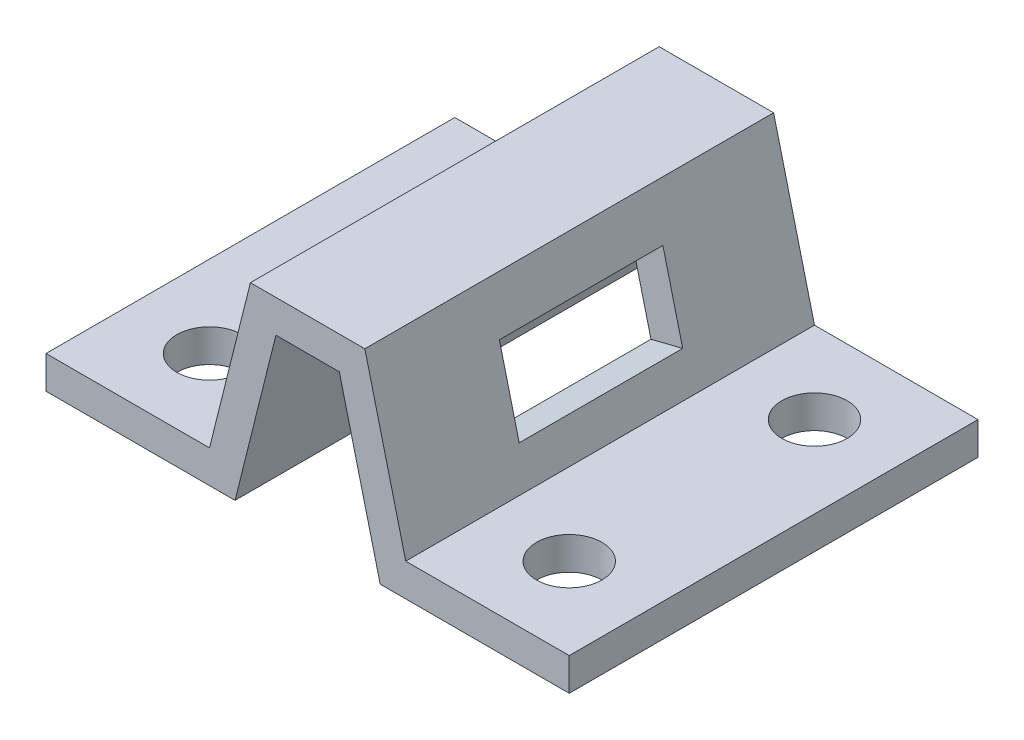
from build123d import *

# Parameters (mm, degrees)
BOSS_EXTRUDE1_DEPTH = 62.5
SKETCH3_R           = 10
CUT_EXTRUDE1_DEPTH  = 125
SKETCH4_W           = 50
SKETCH4_H           = 25
CUT_EXTRUDE2_DEPTH  = 10
SKETCH5_W           = 50
SKETCH5_H           = 25
CUT_EXTRUDE3_DEPTH  = 10


with BuildPart() as part:
    # Sketch2 → Boss-Extrude1 (new body, symmetric)
    with BuildSketch(Plane.XY):
        Polygon((-17.5, 60), (17.5, 60), (30, 10), (80, 10), (80, 0), (22.192235936, 0), (9.692235936, 50), (0, 50), (-9.692235936, 50), (-22.192235936, 0), (-80, 0), (-80, 10), (-30, 10), align=None)
    extrude(amount=BOSS_EXTRUDE1_DEPTH, both=True)

    # Sketch3 → Cut-Extrude1 (cut)
    with BuildSketch(Plane(origin=(0, 10, 0), x_dir=(1, 0, 0), z_dir=(0, 1, 0))):
        with Locations((55, 37.5)):
            Circle(SKETCH3_R)
        with Locations((-55, 37.5)):
            Circle(SKETCH3_R)
        with Locations((-55, -37.5)):
            Circle(SKETCH3_R)
        with Locations((55, -37.5)):
            Circle(SKETCH3_R)
    extrude(amount=-CUT_EXTRUDE1_DEPTH, mode=Mode.SUBTRACT)

    # Sketch4 → Cut-Extrude2 (cut)
    with BuildSketch(Plane(origin=(30.588235294, 7.647058824, 0), x_dir=(0, 0, -1), z_dir=(0.9701425, 0.242535625, 0))):
        with Locations((0, 26.464176571)):
            Rectangle(SKETCH4_W, SKETCH4_H)
    extrude(amount=-CUT_EXTRUDE2_DEPTH, mode=Mode.SUBTRACT)

    # Sketch5 → Cut-Extrude3 (cut)
    with BuildSketch(Plane(origin=(-30.588235294, 7.647058824, 0), x_dir=(0, 0, 1), z_dir=(-0.9701425, 0.242535625, 0))):
        with Locations((0, 26.464176571)):
            Rectangle(SKETCH5_W, SKETCH5_H)
    extrude(amount=-CUT_EXTRUDE3_DEPTH, mode=Mode.SUBTRACT)


solid = part.part
